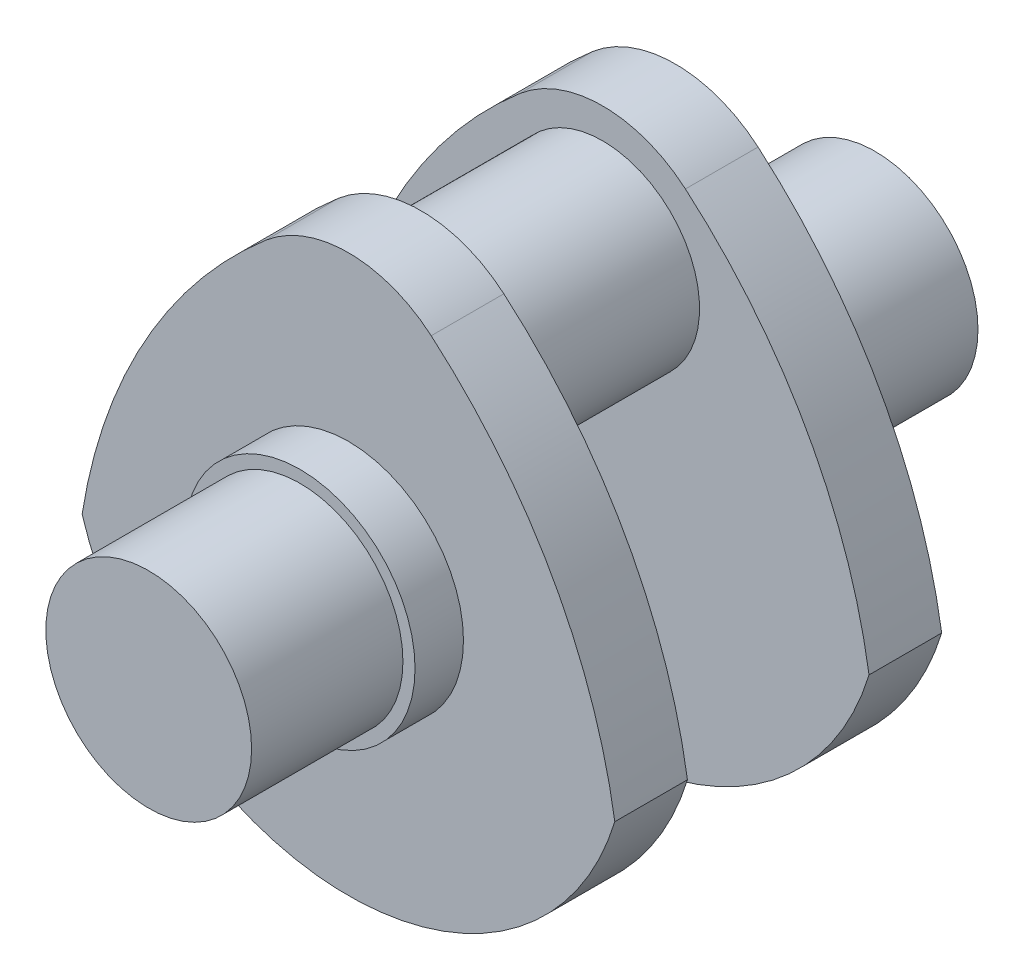
from build123d import *

# Parameters (mm, degrees)
SKETCH1_R           = 170
BOSS_EXTRUDE1_DEPTH = 250
SKETCH2_R           = 190
BOSS_EXTRUDE2_DEPTH = 80
BOSS_EXTRUDE3_DEPTH = 120
SKETCH4_R           = 160
BOSS_EXTRUDE4_DEPTH = 150


with BuildPart() as part:
    # Sketch1 → Boss-Extrude1 (new body)
    with BuildSketch(Plane.XY):
        Circle(SKETCH1_R)
    extrude(amount=BOSS_EXTRUDE1_DEPTH)

    # Sketch2 → Boss-Extrude2 (add)
    with BuildSketch(Plane(origin=(0, 0, 0), x_dir=(-1, 0, 0), z_dir=(0, 0, -1))):
        Circle(SKETCH2_R)
    extrude(amount=BOSS_EXTRUDE2_DEPTH)

    # Sketch3 → Boss-Extrude3 (add)
    with BuildSketch(Plane(origin=(0, 0, -80), x_dir=(-1, 0, 0), z_dir=(0, 0, -1))):
        with BuildLine():
            ThreePointArc((-440, -134.16407865), (0, -460), (440, -134.16407865))
            ThreePointArc((440, -134.16407865), (336.834442487, 164.692576238), (136.680947576, 409.431234611))
            ThreePointArc((136.680947576, 409.431234611), (0, 460), (-136.680947576, 409.431234611))
            ThreePointArc((-136.680947576, 409.431234611), (-336.834442487, 164.692576238), (-440, -134.16407865))
        make_face()
    extrude(amount=BOSS_EXTRUDE3_DEPTH)

    # Sketch4 → Boss-Extrude4 (add)
    with BuildSketch(Plane(origin=(0, 0, -200), x_dir=(-1, 0, 0), z_dir=(0, 0, -1))):
        with Locations((0, 250)):
            Circle(SKETCH4_R)
    extrude(amount=BOSS_EXTRUDE4_DEPTH)

    # Mirror1: part across plane


with BuildPart() as part_1:
    add(part.part)
    add(part.part.mirror(Plane(origin=(0, 250, -350), x_dir=(1, 0, 0), z_dir=(0, 0, -1))))


solid = part_1.part
